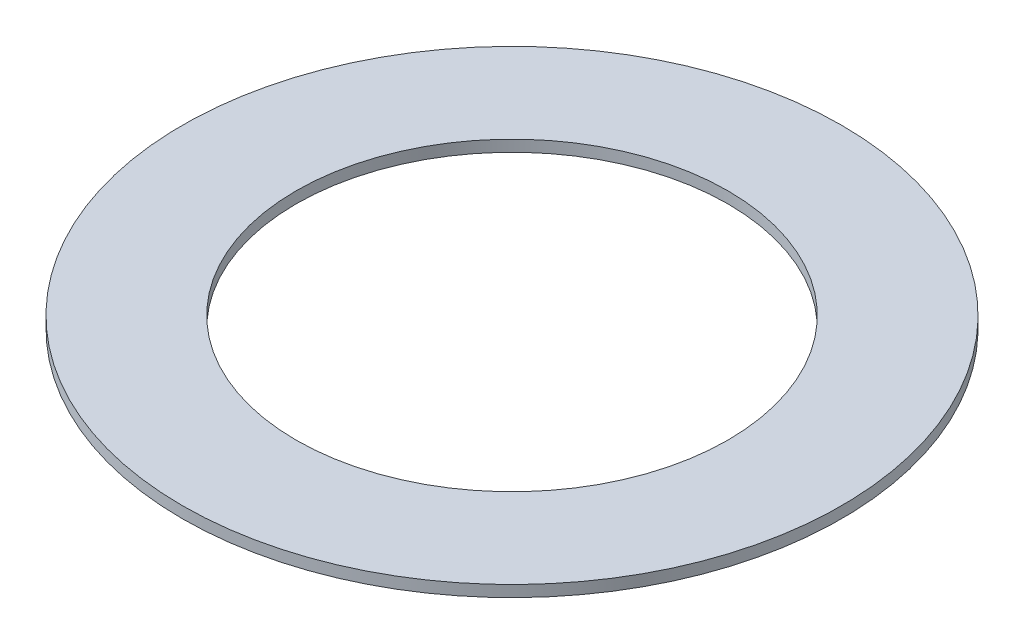
from build123d import *

# Parameters (mm, degrees)
CROQUIS1_R            = 14.5
CROQUIS1_R_2          = 9.5
EXTRUIR_L_MINA1_DEPTH = 0.5


with BuildPart() as part:
    # Croquis1 → Extruir-Lámina1 (new body)
    with BuildSketch(Plane(origin=(0, 0, 0), x_dir=(1, 0, 0), z_dir=(0, 1, 0))):
        Circle(CROQUIS1_R)
        Circle(CROQUIS1_R_2, mode=Mode.SUBTRACT)
    extrude(amount=EXTRUIR_L_MINA1_DEPTH)


solid = part.part
